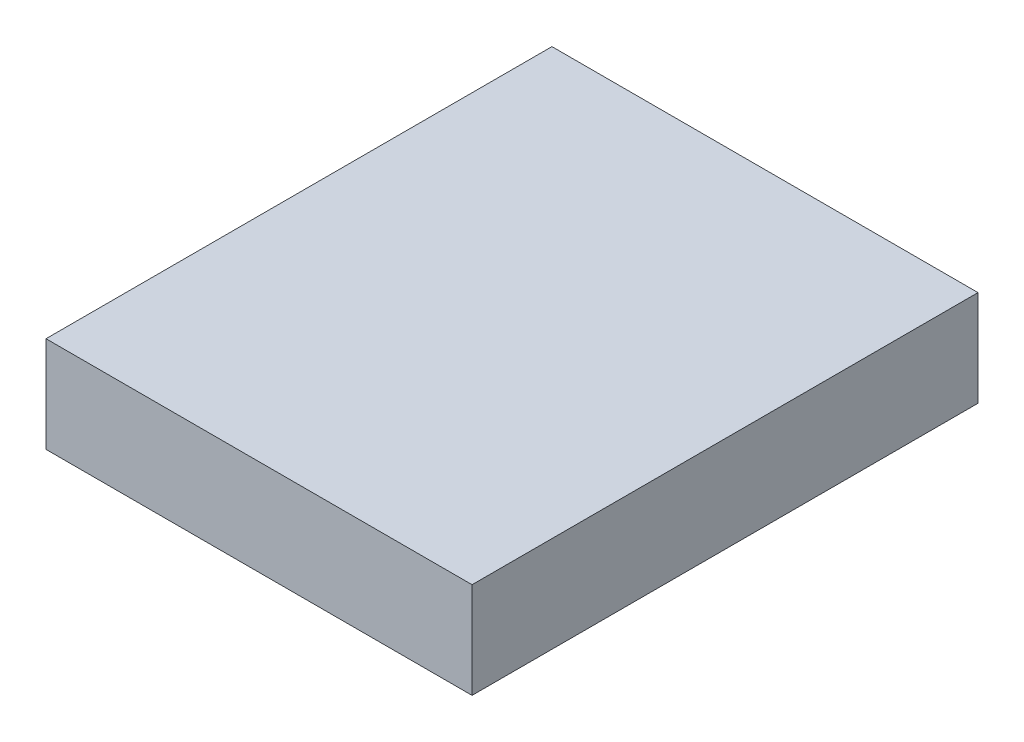
from build123d import *

# Parameters (mm, degrees)
ESQUISSE1_W        = 80
ESQUISSE1_H        = 95
BOSS_EXTRU_1_DEPTH = 18


with BuildPart() as part:
    # Esquisse1 → Boss.-Extru.1 (new body)
    with BuildSketch(Plane(origin=(0, 0, 0), x_dir=(1, 0, 0), z_dir=(0, 1, 0))):
        with Locations((-41.748604281, 3.696594774)):
            Rectangle(ESQUISSE1_W, ESQUISSE1_H)
    extrude(amount=BOSS_EXTRU_1_DEPTH)


solid = part.part
